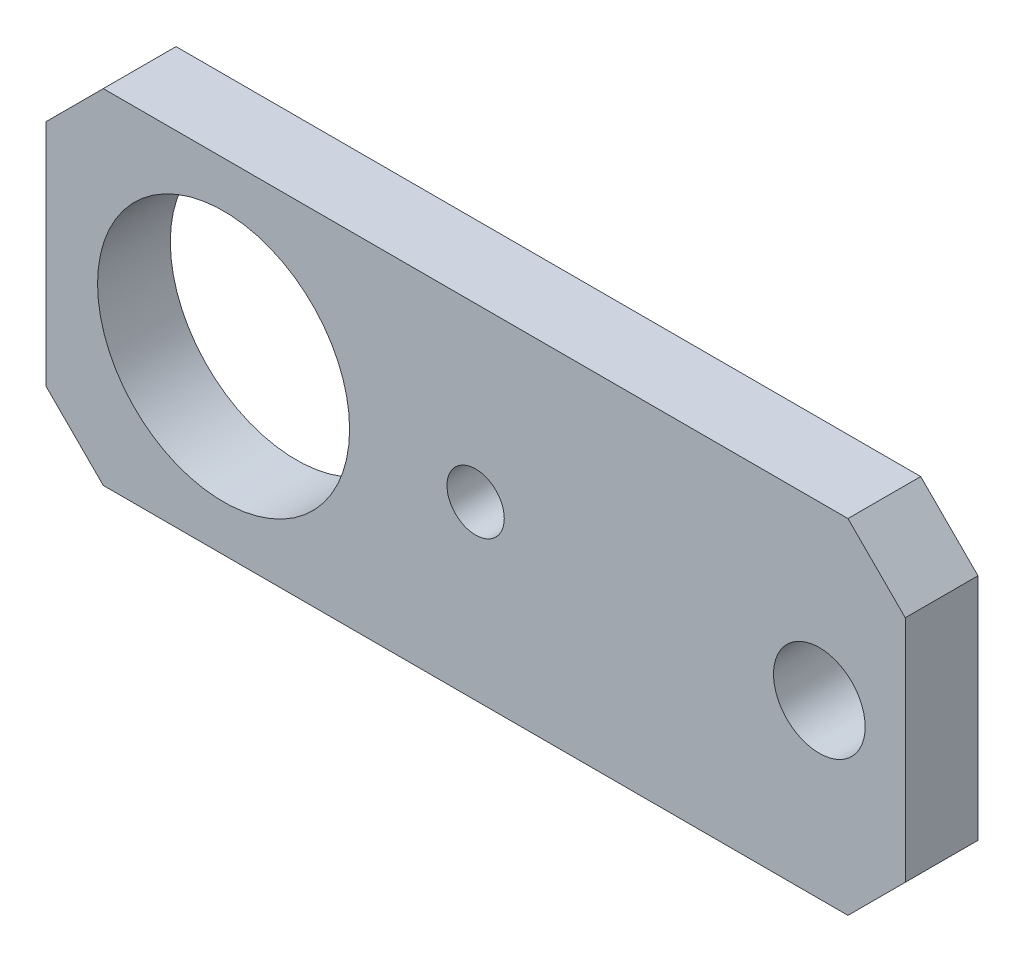
from build123d import *

# Parameters (mm, degrees)
SKETCH1_W           = 75
SKETCH1_H           = 30
SKETCH1_R           = 11
SKETCH1_R_2         = 2.5
SKETCH1_R_3         = 4
BOSS_EXTRUDE1_DEPTH = 6.35
CHAMFER1_SIZE       = 5


with BuildPart() as part:
    # Sketch1 → Boss-Extrude1 (new body)
    with BuildSketch(Plane.XY):
        Rectangle(SKETCH1_W, SKETCH1_H)
        with Locations((-22, 0)):
            Circle(SKETCH1_R, mode=Mode.SUBTRACT)
        Circle(SKETCH1_R_2, mode=Mode.SUBTRACT)
        with Locations((30, 0)):
            Circle(SKETCH1_R_3, mode=Mode.SUBTRACT)
    extrude(amount=BOSS_EXTRUDE1_DEPTH)

    # Chamfer1
    chamfer1_edges = [part.edges().sort_by_distance(p)[0] for p in [
        (37.5, -15, 3.175),
        (-37.5, -15, 3.175),
        (-37.5, 15, 3.175),
        (37.5, 15, 3.175),
    ]]
    chamfer(chamfer1_edges, length=CHAMFER1_SIZE)


solid = part.part
